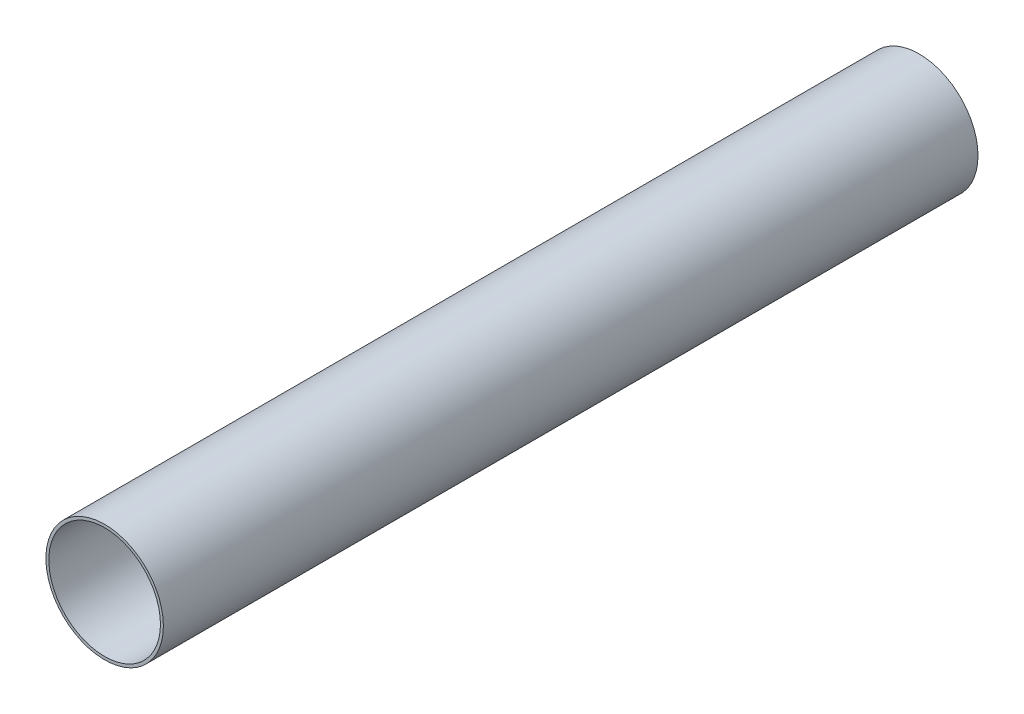
from build123d import *

# Parameters (mm, degrees)
SKETCH1_R           = 15.265
SKETCH1_R_2         = 14.505
BOSS_EXTRUDE1_DEPTH = 211.7


with BuildPart() as part:
    # Sketch1 → Boss-Extrude1 (new body)
    with BuildSketch(Plane.XY):
        Circle(SKETCH1_R)
        Circle(SKETCH1_R_2, mode=Mode.SUBTRACT)
    extrude(amount=BOSS_EXTRUDE1_DEPTH)


solid = part.part
